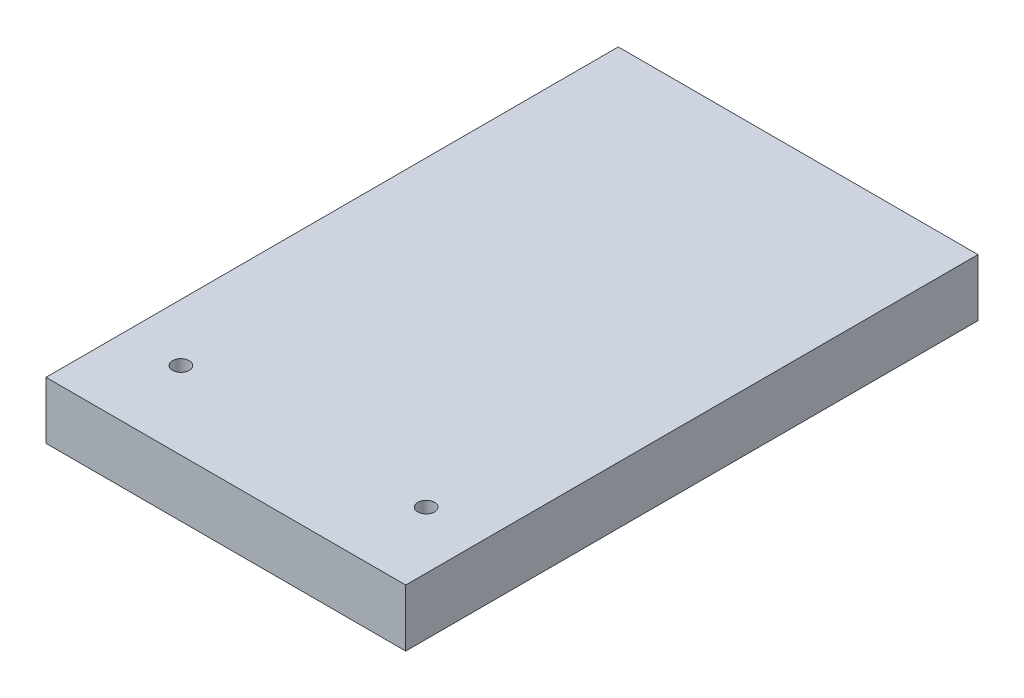
from build123d import *

# Parameters (mm, degrees)
SKETCH1_W           = 88
SKETCH1_H           = 140
BOSS_EXTRUDE1_DEPTH = 14
SKETCH2_R           = 2.05
CUT_EXTRUDE1_DEPTH  = 14


with BuildPart() as part:
    # Sketch1 → Boss-Extrude1 (new body)
    with BuildSketch(Plane(origin=(0, 0, 0), x_dir=(1, 0, 0), z_dir=(0, 1, 0))):
        Rectangle(SKETCH1_W, SKETCH1_H)
    extrude(amount=BOSS_EXTRUDE1_DEPTH)

    # Sketch2 → Cut-Extrude1 (cut)
    with BuildSketch(Plane(origin=(0, 14, 0), x_dir=(1, 0, 0), z_dir=(0, 1, 0))):
        with Locations((-30, -51)):
            Circle(SKETCH2_R)
        with Locations((30, -51)):
            Circle(SKETCH2_R)
    extrude(amount=-CUT_EXTRUDE1_DEPTH, mode=Mode.SUBTRACT)


solid = part.part
